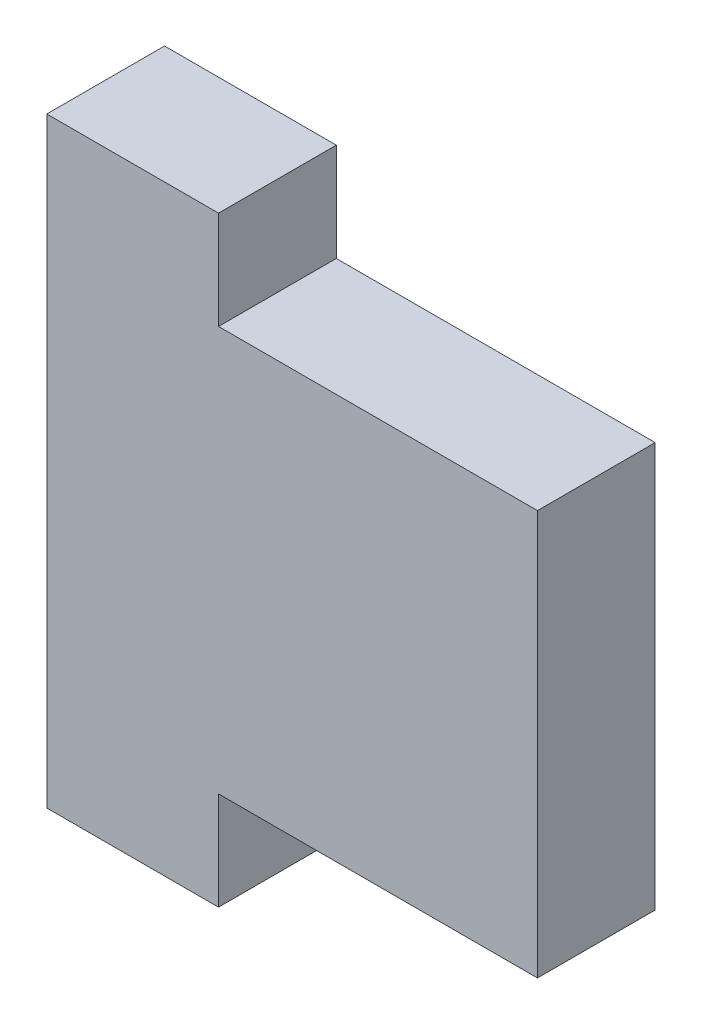
from build123d import *

# Parameters (mm, degrees)
BOSS_EXTRUDE1_DEPTH = 3.048


with BuildPart() as part:
    # Sketch1 → Boss-Extrude1 (new, symmetric)
    with BuildSketch(Plane.XY):
        Polygon((-55.626, 10.4775), (-72.136, 10.4775), (-72.136, 15.5575), (-81.026, 15.5575), (-81.026, -15.5575), (-72.136, -15.5575), (-72.136, -10.4775), (-55.626, -10.4775), align=None)
    extrude(amount=BOSS_EXTRUDE1_DEPTH, both=True)


solid = part.part
